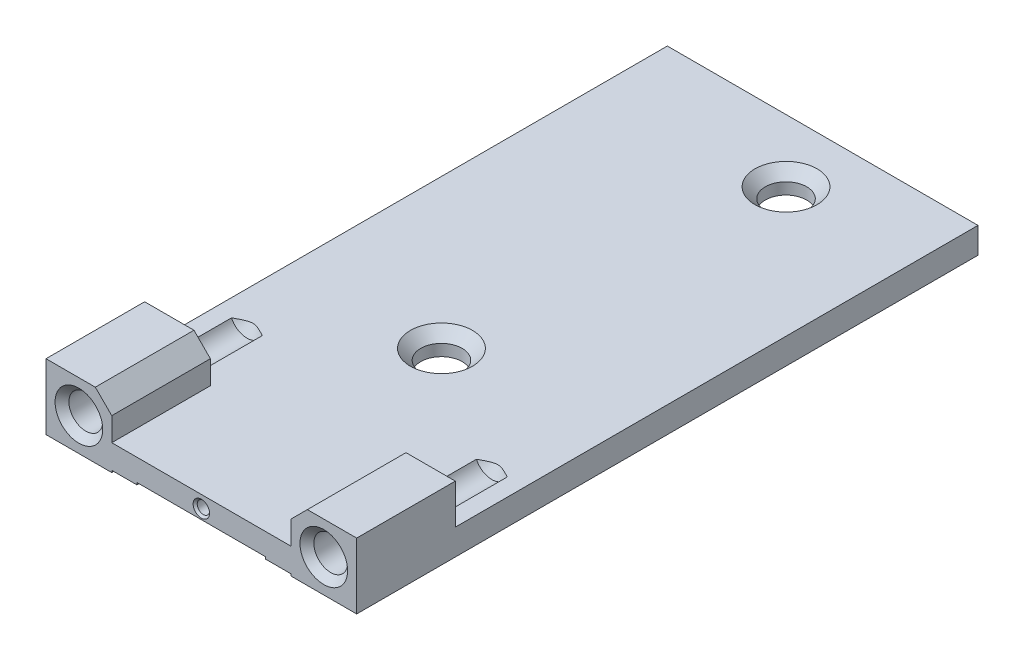
from build123d import *

# Parameters (mm, degrees)
SKETCH1_W                                 = 60
SKETCH1_H                                 = 120
BOSS_EXTRUDE1_DEPTH                       = 12.7
SKETCH2_W                                 = 34.6
SKETCH2_H                                 = 7.7
CUT_EXTRUDE1_DEPTH                        = 121
F_3_32_0_09375_DIAMETER_HOLE3_D           = 2.38125
F_3_32_0_09375_DIAMETER_HOLE3_DEPTH       = 19.05
F_3_32_0_09375_DIAMETER_HOLE3_CSINK_D     = 3.175
F_3_32_0_09375_DIAMETER_HOLE3_CSINK_ANGLE = 90
F_3_32_0_09375_DIAMETER_HOLE3_TIP         = 0.715399675
CUT_EXTRUDE2_DEPTH                        = 1
CUT_EXTRUDE2_DEPTH_BACK                   = 121
F_5_16_18_TAPPED_HOLE1_D                  = 6.5278
F_5_16_18_TAPPED_HOLE1_DEPTH              = 32.45
F_5_16_18_TAPPED_HOLE1_CSINK_D            = 9.2075
F_5_16_18_TAPPED_HOLE1_CSINK_ANGLE        = 90
F_5_16_18_TAPPED_HOLE1_TIP                = 1.961148974
CHAMFER1_SIZE                             = 3.175
SKETCH7_R                                 = 4
CUT_EXTRUDE4_DEPTH                        = 6
CHAMFER2_SIZE                             = 2
SKETCH10_W                                = 60
SKETCH10_H                                = 100.95
CUT_EXTRUDE5_DEPTH                        = 7.7
SKETCH11_W                                = 24.87086649
SKETCH11_H                                = 0.4
CUT_EXTRUDE6_DEPTH                        = 121.0000001
SKETCH12_W                                = 34.6
SKETCH12_H                                = 0.374910819
CUT_EXTRUDE7_DEPTH                        = 121


with BuildPart() as part:
    # Sketch1 → Boss-Extrude1 (new body)
    with BuildSketch(Plane(origin=(0, 0, 0), x_dir=(1, 0, 0), z_dir=(0, 1, 0))):
        with Locations((0, 60)):
            Rectangle(SKETCH1_W, SKETCH1_H)
    extrude(amount=BOSS_EXTRUDE1_DEPTH)

    # Sketch2 → Cut-Extrude1 (cut, through all)
    with BuildSketch(Plane.XY):
        with Locations((0, 8.85)):
            Rectangle(SKETCH2_W, SKETCH2_H)
    extrude(amount=-CUT_EXTRUDE1_DEPTH, mode=Mode.SUBTRACT)

    # 3_32 _0.09375_ Diameter Hole3
    with Locations(Plane.XY):
        with Locations((0, 2.61875)):
            CounterSinkHole(F_3_32_0_09375_DIAMETER_HOLE3_D / 2, F_3_32_0_09375_DIAMETER_HOLE3_CSINK_D / 2, depth=F_3_32_0_09375_DIAMETER_HOLE3_DEPTH, counter_sink_angle=F_3_32_0_09375_DIAMETER_HOLE3_CSINK_ANGLE)
            with Locations((0, 0, -(F_3_32_0_09375_DIAMETER_HOLE3_DEPTH + F_3_32_0_09375_DIAMETER_HOLE3_TIP / 2))):  # 118° drill point
                Cone(0, F_3_32_0_09375_DIAMETER_HOLE3_D / 2, F_3_32_0_09375_DIAMETER_HOLE3_TIP, mode=Mode.SUBTRACT)

    # Sketch3 → Cut-Extrude2 (cut, two sides)
    with BuildSketch(Plane.XY) as cut_extrude2_sk:
        with BuildLine():
            Line((-124.818289263, -9.651397294), (-17.3, 0))
            ThreePointArc((-17.3, 0), (0, 0.774910819), (17.3, 0))
            Line((17.3, 0), (124.818289263, -9.651397294))
            Line((124.818289263, -9.651397294), (124.818289263, -225.552596882))
            Line((124.818289263, -225.552596882), (-124.818289263, -225.552596882))
            Line((-124.818289263, -225.552596882), (-124.818289263, -9.651397294))
        make_face()
    extrude(amount=CUT_EXTRUDE2_DEPTH, mode=Mode.SUBTRACT)
    extrude(cut_extrude2_sk.sketch, amount=-CUT_EXTRUDE2_DEPTH_BACK, mode=Mode.SUBTRACT)

    # 5_16-18 Tapped Hole1
    with Locations(Plane.XY):
        with Locations((-23.65, 6.35), (23.65, 6.35)):
            CounterSinkHole(F_5_16_18_TAPPED_HOLE1_D / 2, F_5_16_18_TAPPED_HOLE1_CSINK_D / 2, depth=F_5_16_18_TAPPED_HOLE1_DEPTH, counter_sink_angle=F_5_16_18_TAPPED_HOLE1_CSINK_ANGLE)
            with Locations((0, 0, -(F_5_16_18_TAPPED_HOLE1_DEPTH + F_5_16_18_TAPPED_HOLE1_TIP / 2))):  # 118° drill point
                Cone(0, F_5_16_18_TAPPED_HOLE1_D / 2, F_5_16_18_TAPPED_HOLE1_TIP, mode=Mode.SUBTRACT)

    # Chamfer1
    chamfer1_edges = [part.edges().sort_by_distance(p)[0] for p in [
        (-17.3, 12.7, -60),
        (17.3, 12.7, -60),
    ]]
    chamfer(chamfer1_edges, length=CHAMFER1_SIZE)

    # Sketch7 → Cut-Extrude4 (cut, through all)
    with BuildSketch(Plane(origin=(0, 5, 0), x_dir=(1, 0, 0), z_dir=(0, 1, 0))):
        with Locations(Location((5, 107.9216, 0), (0, 0, 270))):  # turned: the seam where the file's is
            Circle(SKETCH7_R)
        with Locations(Location((-1.2489, 47.6216, 0), (0, 0, 270))):  # turned: the seam where the file's is
            Circle(SKETCH7_R)
    extrude(amount=-CUT_EXTRUDE4_DEPTH, mode=Mode.SUBTRACT)

    # Chamfer2
    chamfer2_edges = [part.edges().sort_by_distance(p)[0] for p in [
        (5, 5, -111.9216),
        (-1.2489, 5, -51.6216),
    ]]
    chamfer(chamfer2_edges, length=CHAMFER2_SIZE)

    # Sketch10 → Cut-Extrude5 (cut)
    with BuildSketch(Plane(origin=(0, 12.7, 0), x_dir=(1, 0, 0), z_dir=(0, 1, 0))):
        with Locations((0, 69.525)):
            Rectangle(SKETCH10_W, SKETCH10_H)
    extrude(amount=-CUT_EXTRUDE5_DEPTH, mode=Mode.SUBTRACT)

    # Sketch11 → Cut-Extrude6 (cut, through all)
    with BuildSketch(Plane.XY):
        with Locations((0, 0.574910819)):
            Rectangle(SKETCH11_W, SKETCH11_H)
    extrude(amount=-CUT_EXTRUDE6_DEPTH, mode=Mode.SUBTRACT)

    # Sketch12 → Cut-Extrude7 (cut, through all)
    with BuildSketch(Plane.XY):
        with Locations((0, 0.18745541)):
            Rectangle(SKETCH12_W, SKETCH12_H)
    extrude(amount=-CUT_EXTRUDE7_DEPTH, mode=Mode.SUBTRACT)


solid = part.part
